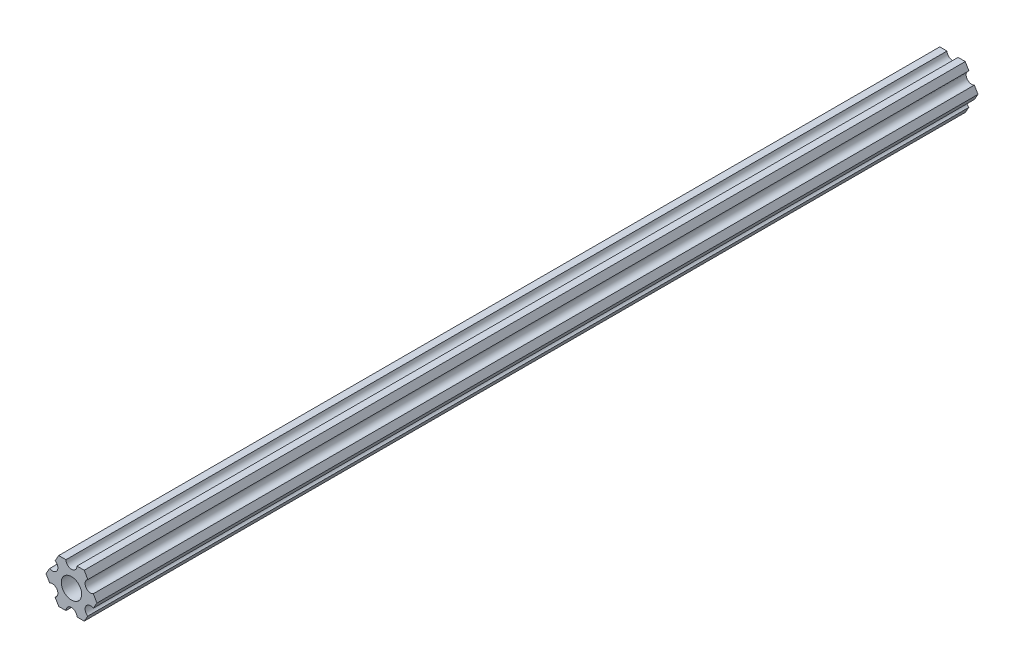
from build123d import *

# Parameters (mm, degrees)
SKETCH1_R           = 2.9337
BOSS_EXTRUDE1_DEPTH = 253.619


with BuildPart() as part:
    # Sketch1 → Boss-Extrude1 (new body)
    with BuildSketch(Plane(origin=(0, 0, 0), x_dir=(-1, 0, 0), z_dir=(0, 0, -1))):
        with BuildLine():
            Line((-4.705511279, -4.549815428), (-3.666174225, -6.350000147))
            Line((-3.666174225, -6.350000147), (-1.5875, -6.350000147))
            ThreePointArc((-1.5875, -6.350000147), (0, -4.762500147), (1.5875, -6.350000147))
            Line((1.5875, -6.350000147), (3.666174225, -6.350000147))
            Line((3.666174225, -6.350000147), (4.705511279, -4.549815428))
            ThreePointArc((4.705511279, -4.549815428), (4.124445879, -2.381250118), (6.293011189, -1.800184719))
            Line((6.293011189, -1.800184719), (7.332348243, 0))
            Line((7.332348243, 0), (6.293011189, 1.800184719))
            ThreePointArc((6.293011189, 1.800184719), (4.124445879, 2.381250118), (4.705511279, 4.549815428))
            Line((4.705511279, 4.549815428), (3.666174225, 6.350000147))
            Line((3.666174225, 6.350000147), (1.5875, 6.350000147))
            ThreePointArc((1.5875, 6.350000147), (0, 4.762500147), (-1.5875, 6.350000147))
            Line((-1.5875, 6.350000147), (-3.666174225, 6.350000147))
            Line((-3.666174225, 6.350000147), (-4.705511279, 4.549815428))
            ThreePointArc((-4.705511279, 4.549815428), (-4.124445879, 2.381250118), (-6.293011189, 1.800184719))
            Line((-6.293011189, 1.800184719), (-7.332348243, 0))
            Line((-7.332348243, 0), (-6.293011189, -1.800184719))
            ThreePointArc((-6.293011189, -1.800184719), (-4.124445879, -2.381250118), (-4.705511279, -4.549815428))
        make_face()
        Circle(SKETCH1_R, mode=Mode.SUBTRACT)
    extrude(amount=-BOSS_EXTRUDE1_DEPTH)


solid = part.part
